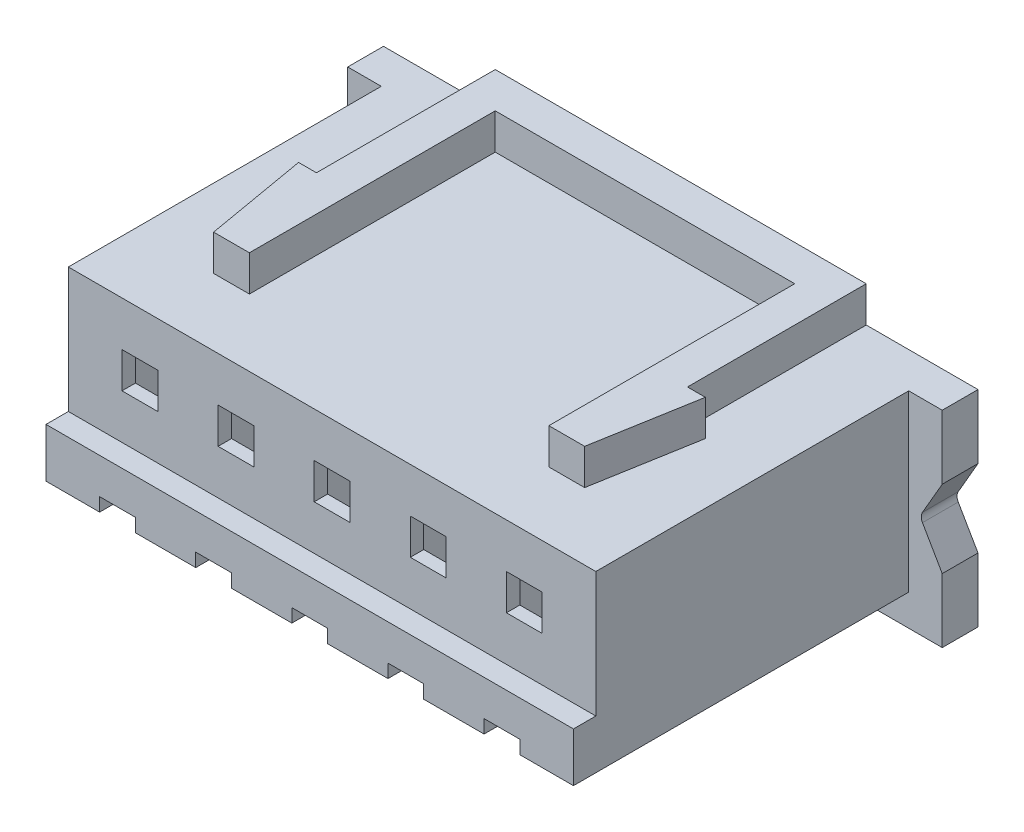
from build123d import *

# Parameters (mm, degrees)
SKETCH1_W           = 11.8
SKETCH1_H           = 4.3
BOSS_EXTRUDE1_DEPTH = 7
SKETCH2_W           = 13.3
SKETCH2_H           = 4.6
BOSS_EXTRUDE2_DEPTH = 0.8
CUT_EXTRUDE1_DEPTH  = 1
FILLET1_R           = 0.2
SKETCH4_W           = 11.8
SKETCH4_H           = 1.5
BOSS_EXTRUDE3_DEPTH = 0.5
SKETCH5_W           = 0.8
SKETCH5_H           = 0.7
CUT_EXTRUDE2_DEPTH  = 3.2
SKETCH6_W           = 0.8
SKETCH6_H           = 0.8
CUT_EXTRUDE3_DEPTH  = 10
BOSS_EXTRUDE4_DEPTH = 0.8
CUT_EXTRUDE4_DEPTH  = 7.5
CUT_EXTRUDE5_DEPTH  = 0.4
BOSS_EXTRUDE5_DEPTH = 0.1


with BuildPart() as part:
    # Sketch1 → Boss-Extrude1 (new body)
    with BuildSketch(Plane.XY):
        Rectangle(SKETCH1_W, SKETCH1_H)
    extrude(amount=BOSS_EXTRUDE1_DEPTH)

    # Sketch2 → Boss-Extrude2 (add)
    with BuildSketch(Plane(origin=(0, 0, 0), x_dir=(-1, 0, 0), z_dir=(0, 0, -1))):
        with Locations((0, -0.15)):
            Rectangle(SKETCH2_W, SKETCH2_H)
    extrude(amount=BOSS_EXTRUDE2_DEPTH)

    # Sketch3 → Cut-Extrude1 (cut)
    with BuildSketch(Plane.XY):
        Polygon((6.15, -0.15), (6.65, -1.016025404), (6.65, 0.716025404), align=None)
    extrude(amount=-CUT_EXTRUDE1_DEPTH, mode=Mode.SUBTRACT)

    # Fillet1
    fillet1_edges = [part.edges().sort_by_distance(p)[0] for p in [
        (6.15, -0.15, -0.4),
    ]]
    fillet(fillet1_edges, radius=FILLET1_R)

    # Sketch4 → Boss-Extrude3 (add)
    with BuildSketch(Plane.XY.offset(7)):
        with Locations((0, -1.4)):
            Rectangle(SKETCH4_W, SKETCH4_H)
    extrude(amount=BOSS_EXTRUDE3_DEPTH)

    # Sketch5 → Cut-Extrude2 (cut)
    with BuildSketch(Plane.XY.offset(7.5)):
        with Locations((-4.3, -1.8)):
            Rectangle(SKETCH5_W, SKETCH5_H)
        with Locations((4.3, -1.8)):
            Rectangle(SKETCH5_W, SKETCH5_H)
        with Locations((2.15, -1.8)):
            Rectangle(SKETCH5_W, SKETCH5_H)
        with Locations((0, -1.8)):
            Rectangle(SKETCH5_W, SKETCH5_H)
        with Locations((-2.15, -1.8)):
            Rectangle(SKETCH5_W, SKETCH5_H)
    extrude(amount=-CUT_EXTRUDE2_DEPTH, mode=Mode.SUBTRACT)

    # Sketch6 → Cut-Extrude3 (cut)
    with BuildSketch(Plane.XY.offset(7)):
        with Locations((-4.3, 0.75)):
            Rectangle(SKETCH6_W, SKETCH6_H)
        with Locations((-2.15, 0.75)):
            Rectangle(SKETCH6_W, SKETCH6_H)
        with Locations((0, 0.75)):
            Rectangle(SKETCH6_W, SKETCH6_H)
        with Locations((2.15, 0.75)):
            Rectangle(SKETCH6_W, SKETCH6_H)
        with Locations((4.3, 0.75)):
            Rectangle(SKETCH6_W, SKETCH6_H)
    extrude(amount=-CUT_EXTRUDE3_DEPTH, mode=Mode.SUBTRACT)

    # Sketch7 → Boss-Extrude4 (add)
    with BuildSketch(Plane(origin=(0, 2.15, 0), x_dir=(1, 0, 0), z_dir=(0, 1, 0))):
        Polygon((-4.15, -5.5), (-4.55, -3.2), (-4.15, -3.2), (-4.15, 0.8), (4.15, 0.8), (4.15, -3.2), (4.55, -3.2), (4.15, -5.5), (3.35, -5.5), (3.35, 0), (-3.35, 0), (-3.35, -5.5), align=None)
    extrude(amount=BOSS_EXTRUDE4_DEPTH)

    # Sketch8 → Cut-Extrude4 (cut)
    with BuildSketch(Plane(origin=(0, 0, -0.8), x_dir=(-1, 0, 0), z_dir=(0, 0, -1))):
        Polygon((5.3, 1.75), (3.3, 1.75), (3.3, -1.05), (3.9, -1.05), (3.9, -1.45), (4.7, -1.45), (4.7, -1.05), (5.3, -1.05), align=None)
        Polygon((3.15, -1.05), (2.55, -1.05), (2.55, -1.45), (1.75, -1.45), (1.75, -1.05), (1.15, -1.05), (1.15, 1.75), (3.15, 1.75), align=None)
        Polygon((1, -1.05), (0.4, -1.05), (0.4, -1.45), (-0.4, -1.45), (-0.4, -1.05), (-1, -1.05), (-1, 1.75), (1, 1.75), align=None)
        Polygon((-1.15, -1.05), (-1.75, -1.05), (-1.75, -1.45), (-2.55, -1.45), (-2.55, -1.05), (-3.15, -1.05), (-3.15, 1.75), (-1.15, 1.75), align=None)
        Polygon((-3.3, -1.05), (-3.9, -1.05), (-3.9, -1.45), (-4.7, -1.45), (-4.7, -1.05), (-5.3, -1.05), (-5.3, 1.75), (-3.3, 1.75), align=None)
    extrude(amount=-CUT_EXTRUDE4_DEPTH, mode=Mode.SUBTRACT)

    # Sketch9 → Cut-Extrude5 (cut)
    with BuildSketch(Plane.XZ.offset(2.15)):
        Polygon((3.9, 4.3), (3.9, 7.5), (2.55, 7.5), (2.55, 4.3), (1.75, 4.3), (1.75, 7.5), (0.4, 7.5), (0.4, 4.3), (-0.4, 4.3), (-0.4, 7.5), (-1.75, 7.5), (-1.75, 4.3), (-2.55, 4.3), (-2.55, 7.5), (-3.9, 7.5), (-3.9, 4.3), (-4.7, 4.3), (-4.7, 7.5), (-5.9, 7.5), (-5.9, 0), (5.9, 0), (5.9, 7.5), (4.7, 7.5), (4.7, 4.3), align=None)
    extrude(amount=-CUT_EXTRUDE5_DEPTH, mode=Mode.SUBTRACT)

    # Sketch10 → Boss-Extrude5 (add)
    with BuildSketch(Plane(origin=(0, 0, -0.8), x_dir=(-1, 0, 0), z_dir=(0, 0, -1))):
        Polygon((-4.288808999, -1.653654724), (-4.196361082, -1.653654724), (-4.196361082, -2.153654724), (-4.241232877, -2.153654724), (-4.241232877, -1.704936776), (-4.318155954, -1.704936776), align=None)
        with BuildLine():
            Line((-2.215591851, -1.807500878), (-2.260463646, -1.807500878))
            add(Edge.make_bspline(
                [(-2.260463646, -1.807500878), (-2.260171196, -1.801547894), (-2.259596831, -1.789856392), (-2.256907075, -1.77281012), (-2.253058378, -1.756516577), (-2.247616742, -1.741106589), (-2.240858702, -1.726443903), (-2.232754413, -1.712586757), (-2.223155291, -1.699588016), (-2.212268615, -1.687568181), (-2.200444524, -1.676541386), (-2.187686532, -1.667019208), (-2.1742801, -1.658973826), (-2.1602659, -1.652247935), (-2.145485819, -1.647199385), (-2.130073983, -1.643453437), (-2.113962677, -1.641199673), (-2.102985531, -1.640957418), (-2.097402749, -1.640834211)],
                knots=[0, 0, 0, 0, 1.7869e-05, 3.5094e-05, 5.1686e-05, 6.8032e-05, 8.4031e-05, 0.000100058, 0.000116104, 0.000132416, 0.000148647, 0.000164532, 0.000180078, 0.00019549, 0.000211074, 0.000226841, 0.000243017, 0.000259759, 0.000259759, 0.000259759, 0.000259759], degree=3))
            add(Edge.make_bspline(
                [(-2.097402749, -1.640834211), (-2.091920166, -1.640962562), (-2.081147089, -1.641214767), (-2.065423944, -1.643380629), (-2.050455759, -1.646772856), (-2.036271792, -1.651532201), (-2.022985212, -1.657929977), (-2.010496205, -1.665615339), (-1.998656089, -1.674503887), (-1.987997977, -1.684968717), (-1.978211109, -1.696140486), (-1.96976793, -1.70806733), (-1.962537478, -1.720385799), (-1.956510666, -1.733189828), (-1.952074075, -1.746599975), (-1.94870576, -1.760421004), (-1.946801843, -1.774795977), (-1.94650964, -1.784525485), (-1.946361082, -1.789472032)],
                knots=[0, 0, 0, 0, 1.6441e-05, 3.2306e-05, 4.7516e-05, 6.2435e-05, 7.7085e-05, 9.1652e-05, 0.000106376, 0.000121393, 0.000136374, 0.000150882, 0.000165157, 0.000179183, 0.000193247, 0.000207458, 0.000221808, 0.000236648, 0.000236648, 0.000236648, 0.000236648], degree=3))
            add(Edge.make_bspline(
                [(-1.946361082, -1.789472032), (-1.946602977, -1.796436008), (-1.947082521, -1.810241753), (-1.951184575, -1.830529591), (-1.957591219, -1.850185793), (-1.965305127, -1.866005408), (-1.973086905, -1.87875305), (-1.980099406, -1.889248579), (-1.988308665, -1.90054936), (-1.997834165, -1.912617551), (-2.008478861, -1.925547681), (-2.02033917, -1.939331937), (-2.033499667, -1.953827904), (-2.042736596, -1.963728705), (-2.047522941, -1.968859051)],
                knots=[0, 0, 0, 0, 2.0874e-05, 4.1382e-05, 6.1843e-05, 8.2763e-05, 9.3997e-05, 0.000106637, 0.000120621, 0.000135888, 0.000152753, 0.000170863, 0.000190435, 0.000211484, 0.000211484, 0.000211484, 0.000211484], degree=3))
            Line((-2.047522941, -1.968859051), (-2.172623101, -2.102372673))
            Line((-2.172623101, -2.102372673), (-1.939950825, -2.102372673))
            Line((-1.939950825, -2.102372673), (-1.939950825, -2.153654724))
            Line((-1.939950825, -2.153654724), (-2.279694415, -2.153654724))
            Line((-2.279694415, -2.153654724), (-2.085784159, -1.946723635))
            add(Edge.make_bspline(
                [(-2.085784159, -1.946723635), (-2.081063032, -1.941795305), (-2.071994714, -1.932328993), (-2.059168632, -1.91850857), (-2.047648776, -1.905687207), (-2.037360577, -1.893889128), (-2.028527219, -1.882941762), (-2.020688329, -1.873199661), (-2.01440753, -1.86423474), (-2.007591045, -1.853843223), (-2.000989048, -1.841155749), (-1.995315854, -1.825650937), (-1.99185659, -1.809689901), (-1.991441613, -1.798903895), (-1.991232877, -1.793478442)],
                knots=[0, 0, 0, 0, 2.0474e-05, 3.9327e-05, 5.6561e-05, 7.2184e-05, 8.6278e-05, 9.8762e-05, 0.000109683, 0.000119101, 0.000136035, 0.000152448, 0.000168517, 0.00018478, 0.00018478, 0.00018478, 0.00018478], degree=3))
            add(Edge.make_bspline(
                [(-1.991232877, -1.793478442), (-1.991323697, -1.790066814), (-1.991502686, -1.78334315), (-1.993082358, -1.773485184), (-1.995469573, -1.763975925), (-1.998890324, -1.754786122), (-2.003405572, -1.746008172), (-2.00890177, -1.737631389), (-2.015243207, -1.729532965), (-2.022579103, -1.721939637), (-2.030637891, -1.714985179), (-2.039151356, -1.708824595), (-2.048158513, -1.703676151), (-2.057621388, -1.699455651), (-2.067513598, -1.696144883), (-2.077854276, -1.6938508), (-2.088614849, -1.692410445), (-2.095962492, -1.692215563), (-2.099706434, -1.692116263)],
                knots=[0, 0, 0, 0, 1.0229e-05, 2.0159e-05, 2.9876e-05, 3.9606e-05, 4.9505e-05, 5.9423e-05, 6.9622e-05, 8.0319e-05, 9.1042e-05, 0.000101521, 0.000111795, 0.000122107, 0.000132559, 0.000143032, 0.000153841, 0.00016507, 0.00016507, 0.00016507, 0.00016507], degree=3))
            add(Edge.make_bspline(
                [(-2.099706434, -1.692116263), (-2.103616553, -1.69221841), (-2.111295381, -1.692419011), (-2.122569529, -1.693822249), (-2.13332464, -1.696243083), (-2.143587769, -1.699554036), (-2.153376281, -1.703762401), (-2.162642573, -1.709004078), (-2.171365843, -1.715258863), (-2.179562489, -1.722350371), (-2.187114486, -1.730245743), (-2.193749754, -1.739047166), (-2.199547471, -1.74859394), (-2.204605933, -1.758860304), (-2.208713888, -1.769939416), (-2.21185291, -1.781791945), (-2.214336745, -1.794366428), (-2.215166534, -1.803050011), (-2.215591851, -1.807500878)],
                knots=[0, 0, 0, 0, 1.1729e-05, 2.3035e-05, 3.4018e-05, 4.4756e-05, 5.5343e-05, 6.5928e-05, 7.6628e-05, 8.7492e-05, 9.8403e-05, 0.00010934, 0.000120489, 0.000131867, 0.000143625, 0.00015587, 0.000168619, 0.000182025, 0.000182025, 0.000182025, 0.000182025], degree=3))
        make_face()
        with BuildLine():
            Line((-0.100207236, -1.76903934), (-0.145079031, -1.76903934))
            add(Edge.make_bspline(
                [(-0.145079031, -1.76903934), (-0.14386338, -1.764006128), (-0.141486884, -1.75416661), (-0.136530088, -1.74010843), (-0.131130194, -1.72680507), (-0.124646036, -1.71450563), (-0.117573357, -1.70296293), (-0.109470111, -1.692438769), (-0.100710151, -1.682665489), (-0.091020872, -1.673992169), (-0.080859635, -1.666138208), (-0.070083261, -1.659441771), (-0.058908562, -1.653681178), (-0.047258114, -1.64893543), (-0.035097232, -1.645360355), (-0.022535858, -1.642766526), (-0.009541072, -1.641082081), (-0.000719988, -1.640917686), (0.00375911, -1.640834211)],
                knots=[0, 0, 0, 0, 1.5524e-05, 3.0347e-05, 4.467e-05, 5.8558e-05, 7.201e-05, 8.5231e-05, 9.8349e-05, 0.000111325, 0.000124187, 0.000136831, 0.000149329, 0.000161865, 0.00017451, 0.000187298, 0.000200318, 0.000213748, 0.000213748, 0.000213748, 0.000213748], degree=3))
            add(Edge.make_bspline(
                [(0.00375911, -1.640834211), (0.010285216, -1.641031244), (0.023195075, -1.641421012), (0.042161225, -1.644980217), (0.06045077, -1.650612379), (0.07786352, -1.65839434), (0.094037582, -1.667992528), (0.108428466, -1.679416062), (0.12084111, -1.692444533), (0.131254593, -1.7068349), (0.139408164, -1.722214258), (0.145420503, -1.738042852), (0.149080743, -1.754283134), (0.149555108, -1.765248459), (0.149792764, -1.770742064)],
                knots=[0, 0, 0, 0, 1.9562e-05, 3.8698e-05, 5.7675e-05, 7.6865e-05, 9.5777e-05, 0.000113954, 0.000131807, 0.000149598, 0.000167073, 0.000183872, 0.000200276, 0.000216747, 0.000216747, 0.000216747, 0.000216747], degree=3))
            add(Edge.make_bspline(
                [(0.149792764, -1.770742064), (0.149626537, -1.776028749), (0.149301256, -1.786373971), (0.146539298, -1.801477042), (0.141891261, -1.815711556), (0.135452723, -1.829137437), (0.127118216, -1.841669557), (0.117022116, -1.853336112), (0.105093165, -1.864188849), (0.096053316, -1.870405917), (0.091399335, -1.873606647)],
                knots=[0, 0, 0, 0, 1.5851e-05, 3.1018e-05, 4.5873e-05, 6.0656e-05, 7.5546e-05, 9.0886e-05, 0.000106841, 0.00012377, 0.00012377, 0.00012377, 0.00012377], degree=3))
            add(Edge.make_bspline(
                [(0.091399335, -1.873606647), (0.096718157, -1.876174958), (0.107256282, -1.881263523), (0.121620643, -1.891242917), (0.13466034, -1.902765252), (0.1419323, -1.91175706), (0.145586034, -1.916274917)],
                knots=[0, 0, 0, 0, 1.7695e-05, 3.5058e-05, 5.2293e-05, 6.9697e-05, 6.9697e-05, 6.9697e-05, 6.9697e-05], degree=3))
            add(Edge.make_bspline(
                [(0.145586034, -1.916274917), (0.14799194, -1.919568881), (0.152764353, -1.926102869), (0.158655144, -1.936608073), (0.163999303, -1.947229714), (0.16816362, -1.958252486), (0.171388458, -1.969548631), (0.173693606, -1.981137545), (0.175125626, -1.993028691), (0.175330705, -2.001073331), (0.17543379, -2.005117064)],
                knots=[0, 0, 0, 0, 1.2226e-05, 2.4252e-05, 3.6078e-05, 4.7871e-05, 5.9538e-05, 7.1285e-05, 8.3286e-05, 9.5416e-05, 9.5416e-05, 9.5416e-05, 9.5416e-05], degree=3))
            add(Edge.make_bspline(
                [(0.17543379, -2.005117064), (0.175177431, -2.012118453), (0.174665919, -2.026088282), (0.170093909, -2.046727528), (0.163006303, -2.066902599), (0.152941026, -2.086199005), (0.140674239, -2.104253345), (0.126080336, -2.120407103), (0.109325135, -2.134292618), (0.090638613, -2.14589408), (0.070393309, -2.155168068), (0.048739653, -2.161604846), (0.025989645, -2.165797132), (0.010388603, -2.166246684), (0.002457027, -2.166475237)],
                knots=[0, 0, 0, 0, 2.098e-05, 4.1862e-05, 6.3119e-05, 8.498e-05, 0.000106955, 0.000128441, 0.000150062, 0.000172018, 0.00019425, 0.000216652, 0.00023964, 0.000263413, 0.000263413, 0.000263413, 0.000263413], degree=3))
            add(Edge.make_bspline(
                [(0.002457027, -2.166475237), (-0.002888587, -2.166351207), (-0.013406974, -2.166107156), (-0.028870331, -2.164438784), (-0.043630573, -2.161391641), (-0.057707659, -2.157291169), (-0.071114092, -2.152092348), (-0.083808965, -2.145618249), (-0.095870378, -2.13800232), (-0.107184514, -2.129154664), (-0.117750024, -2.11925733), (-0.127286127, -2.108134614), (-0.135951812, -2.095992128), (-0.143515046, -2.082688834), (-0.150320325, -2.068396655), (-0.155917604, -2.052932584), (-0.160844114, -2.036434866), (-0.163134609, -2.024938046), (-0.1643098, -2.01903934)],
                knots=[0, 0, 0, 0, 1.6037e-05, 3.1555e-05, 4.6582e-05, 6.1194e-05, 7.5497e-05, 8.9652e-05, 0.000103879, 0.000118224, 0.000132679, 0.000147236, 0.000162105, 0.000177361, 0.000193087, 0.000209535, 0.00022665, 0.000244684, 0.000244684, 0.000244684, 0.000244684], degree=3))
            Line((-0.1643098, -2.01903934), (-0.119438005, -2.01903934))
            add(Edge.make_bspline(
                [(-0.119438005, -2.01903934), (-0.118268963, -2.022889199), (-0.115995076, -2.030377509), (-0.112124462, -2.041154695), (-0.107714709, -2.051034417), (-0.102984057, -2.060089149), (-0.098015708, -2.068408064), (-0.092456433, -2.075771188), (-0.086717984, -2.082501931), (-0.082392362, -2.086294018), (-0.080275345, -2.088149917)],
                knots=[0, 0, 0, 0, 1.207e-05, 2.3476e-05, 3.4328e-05, 4.4497e-05, 5.4117e-05, 6.3352e-05, 7.2152e-05, 8.0588e-05, 8.0588e-05, 8.0588e-05, 8.0588e-05], degree=3))
            add(Edge.make_bspline(
                [(-0.080275345, -2.088149917), (-0.077475834, -2.09030825), (-0.071885453, -2.094618255), (-0.062775706, -2.100118487), (-0.053195008, -2.104884348), (-0.042935769, -2.108524876), (-0.032219373, -2.111607399), (-0.020872607, -2.113624616), (-0.008995576, -2.11500864), (-0.000885895, -2.115130773), (0.003258309, -2.115193186)],
                knots=[0, 0, 0, 0, 1.0597e-05, 2.1162e-05, 3.1867e-05, 4.2641e-05, 5.3771e-05, 6.5283e-05, 7.7174e-05, 8.96e-05, 8.96e-05, 8.96e-05, 8.96e-05], degree=3))
            add(Edge.make_bspline(
                [(0.003258309, -2.115193186), (0.007937381, -2.115105199), (0.017086902, -2.114933149), (0.030437596, -2.113350906), (0.04313866, -2.111046561), (0.055049078, -2.107487563), (0.066324865, -2.103090299), (0.076807958, -2.097569098), (0.086635973, -2.091091281), (0.095683031, -2.083728544), (0.103818103, -2.07566833), (0.110980891, -2.067237891), (0.117070128, -2.058472773), (0.121982068, -2.04932447), (0.125860718, -2.039830866), (0.128501175, -2.029965319), (0.130337106, -2.019808566), (0.130486622, -2.012904428), (0.130561995, -2.009423955)],
                knots=[0, 0, 0, 0, 1.4031e-05, 2.7437e-05, 4.0284e-05, 5.2708e-05, 6.4668e-05, 7.654e-05, 8.818e-05, 9.9927e-05, 0.000111472, 0.000122488, 0.000133073, 0.000143425, 0.000153581, 0.000163762, 0.000174021, 0.000184449, 0.000184449, 0.000184449, 0.000184449], degree=3))
            add(Edge.make_bspline(
                [(0.130561995, -2.009423955), (0.130343381, -2.004765192), (0.129907239, -1.995470848), (0.126577442, -1.981796909), (0.121100462, -1.968622136), (0.11343296, -1.956171309), (0.104099285, -1.944631894), (0.093190012, -1.934335968), (0.080614551, -1.925840241), (0.069040284, -1.919970433), (0.058788119, -1.915965136), (0.050014492, -1.913297284), (0.04019212, -1.911038191), (0.029439785, -1.908936438), (0.017676468, -1.907147674), (0.004914977, -1.905655986), (-0.008847275, -1.904462408), (-0.018374584, -1.903929395), (-0.023284159, -1.903654724)],
                knots=[0, 0, 0, 0, 1.3966e-05, 2.7862e-05, 4.1962e-05, 5.6614e-05, 7.1569e-05, 8.6379e-05, 0.000101437, 0.000116935, 0.000125212, 0.000134432, 0.000144417, 0.000155437, 0.000167294, 0.000180102, 0.000193977, 0.000208728, 0.000208728, 0.000208728, 0.000208728], degree=3))
            Line((-0.023284159, -1.903654724), (-0.023284159, -1.852372673))
            add(Edge.make_bspline(
                [(-0.023284159, -1.852372673), (-0.017098278, -1.852267701), (-0.004981657, -1.852062087), (0.012717529, -1.849575228), (0.029642288, -1.846135138), (0.045417537, -1.840865825), (0.059795925, -1.834745783), (0.072270154, -1.827624039), (0.08266546, -1.819707646), (0.090931328, -1.810874416), (0.097149789, -1.801400838), (0.101696474, -1.791527029), (0.104382235, -1.781166449), (0.104740759, -1.774095782), (0.104920969, -1.770541744)],
                knots=[0, 0, 0, 0, 1.8543e-05, 3.6321e-05, 5.353e-05, 7.0285e-05, 8.612e-05, 0.000100345, 0.000113267, 0.000125173, 0.000136452, 0.00014712, 0.000157663, 0.000168319, 0.000168319, 0.000168319, 0.000168319], degree=3))
            add(Edge.make_bspline(
                [(0.104920969, -1.770541744), (0.104861768, -1.767930637), (0.104743989, -1.762735965), (0.103258664, -1.755146669), (0.101026658, -1.747789391), (0.097958125, -1.740695418), (0.093850954, -1.73391395), (0.088935813, -1.727387172), (0.083083227, -1.721152347), (0.076376735, -1.715340872), (0.069175048, -1.70980241), (0.061282223, -1.705100462), (0.052936241, -1.701079739), (0.044127862, -1.697764095), (0.034828501, -1.695269911), (0.025081849, -1.693479077), (0.014869323, -1.692359412), (0.007901933, -1.69219821), (0.004360072, -1.692116263)],
                knots=[0, 0, 0, 0, 7.823e-06, 1.5563e-05, 2.3104e-05, 3.0863e-05, 3.8679e-05, 4.6832e-05, 5.5336e-05, 6.4278e-05, 7.3432e-05, 8.2553e-05, 9.1782e-05, 0.000101195, 0.000110744, 0.000120626, 0.000130901, 0.000141526, 0.000141526, 0.000141526, 0.000141526], degree=3))
            add(Edge.make_bspline(
                [(0.004360072, -1.692116263), (-0.001333023, -1.692315029), (-0.012452963, -1.692703265), (-0.028483665, -1.696103695), (-0.043386427, -1.701529136), (-0.054777665, -1.708005282), (-0.063189462, -1.714398201), (-0.069200453, -1.719981399), (-0.075103383, -1.726186088), (-0.080509908, -1.733394427), (-0.085977619, -1.741118254), (-0.090955414, -1.749750209), (-0.095792513, -1.759065122), (-0.098707163, -1.765650213), (-0.100207236, -1.76903934)],
                knots=[0, 0, 0, 0, 1.7063e-05, 3.3328e-05, 4.8919e-05, 6.4486e-05, 7.2419e-05, 8.0571e-05, 8.9075e-05, 9.807e-05, 0.000107572, 0.00011745, 0.000127932, 0.000139048, 0.000139048, 0.000139048, 0.000139048], degree=3))
        make_face()
        Polygon((2.224011514, -1.640834211), (2.233126098, -1.640834211), (2.233126098, -1.986988058), (2.290818405, -1.986988058), (2.290818405, -2.038270109), (2.233126098, -2.038270109), (2.233126098, -2.153654724), (2.188254303, -2.153654724), (2.188254303, -2.038270109), (1.951074816, -2.038270109), align=None)
        Polygon((2.188254303, -1.986988058), (2.188254303, -1.769840622), (2.039215841, -1.986988058), align=None, mode=Mode.SUBTRACT)
        with BuildLine():
            Line((4.380561995, -1.653654724), (4.380561995, -1.704936776))
            Line((4.380561995, -1.704936776), (4.21048988, -1.704936776))
            Line((4.21048988, -1.704936776), (4.183546771, -1.836447192))
            add(Edge.make_bspline(
                [(4.183546771, -1.836447192), (4.188840467, -1.834985725), (4.199096166, -1.832154363), (4.214233289, -1.829010681), (4.228603604, -1.827115618), (4.237928657, -1.826856859), (4.242441001, -1.826731647)],
                knots=[0, 0, 0, 0, 1.6472e-05, 3.1911e-05, 4.6347e-05, 5.9882e-05, 5.9882e-05, 5.9882e-05, 5.9882e-05], degree=3))
            add(Edge.make_bspline(
                [(4.242441001, -1.826731647), (4.248024393, -1.826852495), (4.259002735, -1.827090113), (4.275065442, -1.829371805), (4.290398713, -1.832963222), (4.30497048, -1.837980439), (4.318807701, -1.844396115), (4.331783067, -1.852410392), (4.34409134, -1.861772297), (4.355511711, -1.87253587), (4.365872326, -1.884381815), (4.374981754, -1.897118654), (4.382719266, -1.910622606), (4.388942231, -1.925022693), (4.393911422, -1.940159715), (4.39721885, -1.956192941), (4.399421237, -1.972971244), (4.399667292, -1.984443325), (4.399792764, -1.990293346)],
                knots=[0, 0, 0, 0, 1.6741e-05, 3.2918e-05, 4.8563e-05, 6.3926e-05, 7.9071e-05, 9.4222e-05, 0.000109587, 0.000125389, 0.000141218, 0.000156727, 0.000172294, 0.000187813, 0.000203714, 0.000219999, 0.000236858, 0.0002544, 0.0002544, 0.0002544, 0.0002544], degree=3))
            add(Edge.make_bspline(
                [(4.399792764, -1.990293346), (4.399697754, -1.994367949), (4.399509016, -2.00246209), (4.398549218, -2.01448269), (4.396701258, -2.026248809), (4.394220155, -2.037762008), (4.39099981, -2.04900049), (4.387101373, -2.059996422), (4.382330512, -2.070681366), (4.377097459, -2.081156423), (4.371205105, -2.091184781), (4.364665318, -2.100563207), (4.357755962, -2.10943239), (4.350321478, -2.117697209), (4.342292765, -2.125303355), (4.333767055, -2.132295966), (4.324812381, -2.138793299), (4.315290203, -2.144531613), (4.305412706, -2.149812035), (4.295037246, -2.154143969), (4.284400003, -2.158016902), (4.273347878, -2.161103977), (4.261905905, -2.163522914), (4.250055223, -2.165165856), (4.237857984, -2.16636249), (4.229590125, -2.166437399), (4.225413758, -2.166475237)],
                knots=[0, 0, 0, 0, 1.2226e-05, 2.4287e-05, 3.6144e-05, 4.7931e-05, 5.9598e-05, 7.1193e-05, 8.2899e-05, 9.4679e-05, 0.000106309, 0.000117755, 0.000128956, 0.000140019, 0.000151071, 0.0001621, 0.00017308, 0.000184228, 0.000195429, 0.000206647, 0.000217926, 0.000229373, 0.000241041, 0.000252982, 0.000265251, 0.000277775, 0.000277775, 0.000277775, 0.000277775], degree=3))
            add(Edge.make_bspline(
                [(4.225413758, -2.166475237), (4.220431732, -2.166376546), (4.210630185, -2.166182383), (4.196270104, -2.164151171), (4.182453732, -2.16124204), (4.169292289, -2.15686543), (4.156667822, -2.15138153), (4.144750291, -2.144450649), (4.13323518, -2.136596491), (4.122590604, -2.127327869), (4.112711159, -2.117197058), (4.103867372, -2.106203109), (4.095991147, -2.094527474), (4.089208611, -2.082113452), (4.08342318, -2.068993662), (4.078878181, -2.055118948), (4.075209845, -2.040561804), (4.073657928, -2.030539874), (4.072869687, -2.025449596)],
                knots=[0, 0, 0, 0, 1.4936e-05, 2.9385e-05, 4.3432e-05, 5.7242e-05, 7.092e-05, 8.4648e-05, 9.854e-05, 0.000112674, 0.000126911, 0.000140942, 0.000154943, 0.000169108, 0.000183326, 0.000197895, 0.00021286, 0.000228305, 0.000228305, 0.000228305, 0.000228305], degree=3))
            Line((4.072869687, -2.025449596), (4.117741482, -2.025449596))
            add(Edge.make_bspline(
                [(4.117741482, -2.025449596), (4.118845562, -2.030217661), (4.120967664, -2.039382146), (4.125625628, -2.052258052), (4.131320753, -2.063732226), (4.138092803, -2.073956453), (4.146171379, -2.082872024), (4.155389869, -2.090817318), (4.165725258, -2.097985194), (4.177210005, -2.103959875), (4.189326159, -2.109055411), (4.202007189, -2.11244851), (4.21490781, -2.114834352), (4.223633291, -2.115073175), (4.228017925, -2.115193186)],
                knots=[0, 0, 0, 0, 1.4673e-05, 2.8202e-05, 4.0968e-05, 5.3024e-05, 6.4869e-05, 7.6939e-05, 8.9469e-05, 0.000102507, 0.000115713, 0.000128811, 0.00014182, 0.00015496, 0.00015496, 0.00015496, 0.00015496], degree=3))
            add(Edge.make_bspline(
                [(4.228017925, -2.115193186), (4.232297702, -2.115075932), (4.24072462, -2.114845058), (4.253126246, -2.113068056), (4.265099514, -2.11033126), (4.276526279, -2.106235567), (4.287606499, -2.10125775), (4.298059895, -2.094869882), (4.308188878, -2.08751845), (4.317678611, -2.079096075), (4.326369961, -2.06981469), (4.334049407, -2.059889348), (4.340446109, -2.049301227), (4.345836696, -2.038233634), (4.349930024, -2.026565268), (4.352850164, -2.014350815), (4.354564887, -2.001560103), (4.35480077, -1.992835916), (4.354920969, -1.988390301)],
                knots=[0, 0, 0, 0, 1.2835e-05, 2.5271e-05, 3.7516e-05, 4.9617e-05, 6.1628e-05, 7.3893e-05, 8.6294e-05, 9.9136e-05, 0.000111892, 0.000124393, 0.000136709, 0.000148939, 0.000161262, 0.000173724, 0.000186558, 0.000199893, 0.000199893, 0.000199893, 0.000199893], degree=3))
            add(Edge.make_bspline(
                [(4.354920969, -1.988390301), (4.354826901, -1.98437948), (4.354642775, -1.976528867), (4.353138408, -1.965043266), (4.350521698, -1.954175688), (4.346889715, -1.943873655), (4.342278357, -1.934127449), (4.336643169, -1.924927012), (4.329878398, -1.916393607), (4.322150985, -1.908523242), (4.313685551, -1.901259689), (4.304336445, -1.895067676), (4.294299312, -1.889858545), (4.283695084, -1.885363117), (4.272271527, -1.882134439), (4.260254865, -1.879710455), (4.247515336, -1.878308261), (4.238805237, -1.878113705), (4.234328021, -1.878013699)],
                knots=[0, 0, 0, 0, 1.203e-05, 2.3546e-05, 3.4673e-05, 4.5507e-05, 5.6259e-05, 6.6962e-05, 7.7802e-05, 8.8851e-05, 0.000100009, 0.000111204, 0.000122404, 0.0001339, 0.000145691, 0.000157948, 0.000170646, 0.000184077, 0.000184077, 0.000184077, 0.000184077], degree=3))
            add(Edge.make_bspline(
                [(4.234328021, -1.878013699), (4.230452459, -1.87809664), (4.222450409, -1.878267894), (4.210175719, -1.879528822), (4.197276902, -1.881563007), (4.183803402, -1.884361042), (4.169714758, -1.888022624), (4.155040701, -1.89241041), (4.139750377, -1.89765641), (4.129447845, -1.901618155), (4.124151739, -1.903654724)],
                knots=[0, 0, 0, 0, 1.1625e-05, 2.4004e-05, 3.698e-05, 5.0789e-05, 6.5268e-05, 8.0637e-05, 9.6727e-05, 0.000113749, 0.000113749, 0.000113749, 0.000113749], degree=3))
            Line((4.124151739, -1.903654724), (4.17543379, -1.653654724))
            Line((4.17543379, -1.653654724), (4.380561995, -1.653654724))
        make_face()
    extrude(amount=BOSS_EXTRUDE5_DEPTH)


solid = part.part
